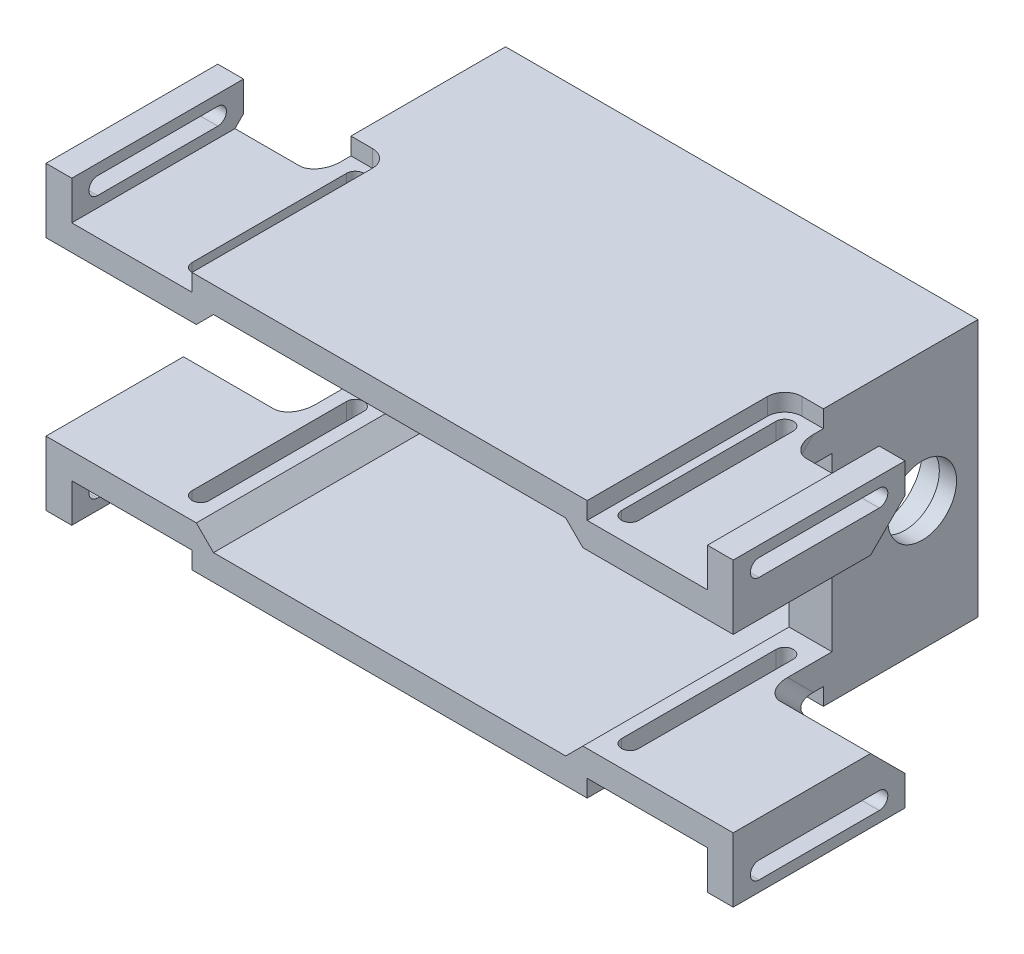
from build123d import *

# Parameters (mm, degrees)
SKIZZE2_W                       = 55
SKIZZE2_H                       = 30
SKIZZE2_W_2                     = 45
SKIZZE2_H_2                     = 24
AUFSATZ_LINEAR_AUSTRAGEN1_DEPTH = 41
SKIZZE5_W                       = 55
SKIZZE5_H                       = 20
SCHNITT_LINEAR_AUSTRAGEN3_DEPTH = 24
SKIZZE4_R                       = 4
SCHNITT_LINEAR_AUSTRAGEN1_DEPTH = 51
SKIZZE4_3_R                     = 5
SCHNITT_LINEAR_AUSTRAGEN2_DEPTH = 3
SCHNITT_LINEAR_AUSTRAGEN4_DEPTH = 5
SCHNITT_LINEAR_AUSTRAGEN5_DEPTH = 2
AUFSATZ_LINEAR_AUSTRAGEN2_DEPTH = 20
SCHNITT_LINEAR_AUSTRAGEN6_DEPTH = 4
SPIEGELN1_COPY_1_DEPTH          = 5
SPIEGELN1_COPY_2_DEPTH          = 2
SPIEGELN1_COPY_3_DEPTH          = 20
SPIEGELN1_COPY_4_DEPTH          = 4
FASE2_SIZE                      = 2
FASE3_SIZE                      = 4
VERRUNDUNG1_R                   = 2


with BuildPart() as part:
    # Skizze2 → Aufsatz-Linear austragen1 (new body)
    with BuildSketch(Plane.XY.offset(82)):
        Rectangle(SKIZZE2_W, SKIZZE2_H)
        Rectangle(SKIZZE2_W_2, SKIZZE2_H_2, mode=Mode.SUBTRACT)
    extrude(amount=-AUFSATZ_LINEAR_AUSTRAGEN1_DEPTH)

    # Skizze5 → Schnitt-Linear austragen3 (cut)
    with BuildSketch(Plane.XY.offset(82)):
        Rectangle(SKIZZE5_W, SKIZZE5_H)
    extrude(amount=-SCHNITT_LINEAR_AUSTRAGEN3_DEPTH, mode=Mode.SUBTRACT)

    # Skizze4 → Schnitt-Linear austragen1 (cut, through all)
    with BuildSketch(Plane(origin=(22.5, 0, 0), x_dir=(0, 0, -1), z_dir=(1, 0, 0))):
        with Locations((-47.5, 0)):
            Circle(SKIZZE4_R)
    schnitt_linear_austragen1 = extrude(amount=-SCHNITT_LINEAR_AUSTRAGEN1_DEPTH, mode=Mode.SUBTRACT)

    # Skizze4_3 → Schnitt-Linear austragen2 (cut)
    with BuildSketch(Plane(origin=(22.5, 0, 0), x_dir=(0, 0, -1), z_dir=(1, 0, 0))):
        with Locations((-47.5, 0)):
            Circle(SKIZZE4_3_R)
    schnitt_linear_austragen2 = extrude(amount=SCHNITT_LINEAR_AUSTRAGEN2_DEPTH, mode=Mode.SUBTRACT)

    # Skizze6 → Schnitt-Linear austragen4 (cut)
    with BuildSketch(Plane(origin=(0, 15, 0), x_dir=(1, 0, 0), z_dir=(0, 1, 0))):
        with BuildLine():
            Line((26, -61), (26, -79))
            ThreePointArc((26, -79), (25, -80), (24, -79))
            Line((24, -79), (24, -61))
            ThreePointArc((24, -61), (25, -60), (26, -61))
        make_face()
    schnitt_linear_austragen4 = extrude(amount=-SCHNITT_LINEAR_AUSTRAGEN4_DEPTH, mode=Mode.SUBTRACT)

    # Skizze6_3 → Schnitt-Linear austragen5 (cut)
    with BuildSketch(Plane(origin=(0, 15, 0), x_dir=(1, 0, 0), z_dir=(0, 1, 0))):
        with BuildLine():
            Line((23, -61), (23, -79))
            ThreePointArc((23, -79), (25, -81), (27, -79))
            Line((27, -79), (27, -61))
            ThreePointArc((27, -61), (25, -59), (23, -61))
        make_face()
        with BuildLine():
            ThreePointArc((24, -79), (25, -80), (26, -79))
            Line((26, -79), (26, -61))
            ThreePointArc((26, -61), (25, -60), (24, -61))
            Line((24, -61), (24, -79))
        make_face(mode=Mode.SUBTRACT)
        with BuildLine():
            ThreePointArc((25, -59), (26.414213562, -59.585786438), (27, -61))
            Line((27, -61), (27, -79))
            ThreePointArc((27, -79), (25, -81), (23, -79))
            Line((23, -79), (23, -82))
            Line((23, -82), (27.5, -82))
            Line((27.5, -82), (27.5, -59))
            Line((27.5, -59), (25, -59))
        make_face()
    schnitt_linear_austragen5 = extrude(amount=-SCHNITT_LINEAR_AUSTRAGEN5_DEPTH, mode=Mode.SUBTRACT)

    # Skizze8 → Aufsatz-Linear austragen2 (add)
    with BuildSketch(Plane.XY.offset(82)):
        Polygon((27.5, 13), (37, 13), (37, 17.5), (40, 17.5), (40, 10), (27.5, 10), align=None)
    aufsatz_linear_austragen2 = extrude(amount=-AUFSATZ_LINEAR_AUSTRAGEN2_DEPTH)

    # Skizze9 → Schnitt-Linear austragen6 (cut, through all)
    with BuildSketch(Plane.ZY.offset(-37)):
        with BuildLine():
            Line((65, 16.25), (79, 16.25))
            ThreePointArc((79, 16.25), (80, 15.25), (79, 14.25))
            Line((79, 14.25), (65, 14.25))
            ThreePointArc((65, 14.25), (64, 15.25), (65, 16.25))
        make_face()
    schnitt_linear_austragen6 = extrude(amount=-SCHNITT_LINEAR_AUSTRAGEN6_DEPTH, mode=Mode.SUBTRACT)

    # Spiegeln2: Schnitt-Linear austragen4, Schnitt-Linear austragen5, Aufsatz-Linear austragen2, Schnitt-Linear austragen6 across plane
    add(schnitt_linear_austragen4.mirror(Plane.ZX), mode=Mode.SUBTRACT)
    add(schnitt_linear_austragen5.mirror(Plane.ZX), mode=Mode.SUBTRACT)
    add(aufsatz_linear_austragen2.mirror(Plane.ZX))
    add(schnitt_linear_austragen6.mirror(Plane.ZX), mode=Mode.SUBTRACT)

    # Spiegeln1: Schnitt-Linear austragen2, Schnitt-Linear austragen1, Schnitt-Linear austragen4, Schnitt-Linear austragen5, Aufsatz-Linear austragen2, Schnitt-Linear austragen6 across plane
    add(schnitt_linear_austragen2.mirror(Plane(origin=(0, 0, 0), x_dir=(0, 0, 1), z_dir=(1, 0, 0))), mode=Mode.SUBTRACT)
    add(schnitt_linear_austragen1.mirror(Plane(origin=(0, 0, 0), x_dir=(0, 0, 1), z_dir=(1, 0, 0))), mode=Mode.SUBTRACT)
    add(schnitt_linear_austragen4.mirror(Plane(origin=(0, 0, 0), x_dir=(0, 0, 1), z_dir=(1, 0, 0))), mode=Mode.SUBTRACT)
    add(schnitt_linear_austragen5.mirror(Plane(origin=(0, 0, 0), x_dir=(0, 0, 1), z_dir=(1, 0, 0))), mode=Mode.SUBTRACT)
    add(aufsatz_linear_austragen2.mirror(Plane(origin=(0, 0, 0), x_dir=(0, 0, 1), z_dir=(1, 0, 0))))
    add(schnitt_linear_austragen6.mirror(Plane(origin=(0, 0, 0), x_dir=(0, 0, 1), z_dir=(1, 0, 0))), mode=Mode.SUBTRACT)

    # Spiegeln1 copy 1 sketch → Spiegeln1 copy 1 (cut)
    with BuildSketch(Plane(origin=(0, -15, 0), x_dir=(-1, 0, 0), z_dir=(0, -1, 0))):
        with BuildLine():
            Line((26, -61), (26, -79))
            ThreePointArc((26, -79), (25, -80), (24, -79))
            Line((24, -79), (24, -61))
            ThreePointArc((24, -61), (25, -60), (26, -61))
        make_face()
    extrude(amount=-SPIEGELN1_COPY_1_DEPTH, mode=Mode.SUBTRACT)

    # Spiegeln1 copy 2 sketch → Spiegeln1 copy 2 (cut)
    with BuildSketch(Plane(origin=(0, -15, 0), x_dir=(-1, 0, 0), z_dir=(0, -1, 0))):
        with BuildLine():
            Line((23, -61), (23, -79))
            ThreePointArc((23, -79), (25, -81), (27, -79))
            Line((27, -79), (27, -61))
            ThreePointArc((27, -61), (25, -59), (23, -61))
        make_face()
        with BuildLine():
            ThreePointArc((24, -79), (25, -80), (26, -79))
            Line((26, -79), (26, -61))
            ThreePointArc((26, -61), (25, -60), (24, -61))
            Line((24, -61), (24, -79))
        make_face(mode=Mode.SUBTRACT)
        with BuildLine():
            ThreePointArc((25, -59), (26.414213562, -59.585786438), (27, -61))
            Line((27, -61), (27, -79))
            ThreePointArc((27, -79), (25, -81), (23, -79))
            Line((23, -79), (23, -82))
            Line((23, -82), (27.5, -82))
            Line((27.5, -82), (27.5, -59))
            Line((27.5, -59), (25, -59))
        make_face()
    extrude(amount=-SPIEGELN1_COPY_2_DEPTH, mode=Mode.SUBTRACT)

    # Spiegeln1 copy 3 sketch → Spiegeln1 copy 3 (add)
    with BuildSketch(Plane(origin=(0, 0, 82), x_dir=(-1, 0, 0), z_dir=(0, 0, 1))):
        Polygon((27.5, 13), (37, 13), (37, 17.5), (40, 17.5), (40, 10), (27.5, 10), align=None)
    extrude(amount=-SPIEGELN1_COPY_3_DEPTH)

    # Spiegeln1 copy 4 sketch → Spiegeln1 copy 4 (cut, through all)
    with BuildSketch(Plane(origin=(-37, 0, 0), x_dir=(0, 0, 1), z_dir=(1, 0, 0))):
        with BuildLine():
            Line((65, 16.25), (79, 16.25))
            ThreePointArc((79, 16.25), (80, 15.25), (79, 14.25))
            Line((79, 14.25), (65, 14.25))
            ThreePointArc((65, 14.25), (64, 15.25), (65, 16.25))
        make_face()
    extrude(amount=-SPIEGELN1_COPY_4_DEPTH, mode=Mode.SUBTRACT)

    # Fase2
    fase2_edges = [part.edges().sort_by_distance(p)[0] for p in [
        (-22.5, 12, 61.5),
        (-22.5, -12, 61.5),
        (22.5, -12, 61.5),
        (22.5, 12, 61.5),
    ]]
    chamfer(fase2_edges, length=FASE2_SIZE)

    # Fase3
    fase3_edges = [part.edges().sort_by_distance(p)[0] for p in [
        (-33.75, 10, 62),
        (-33.75, -10, 62),
        (33.75, -10, 62),
        (33.75, 10, 62),
    ]]
    chamfer(fase3_edges, length=FASE3_SIZE)

    # Verrundung1
    verrundung1_edges = [part.edges().sort_by_distance(p)[0] for p in [
        (-27.5, 11.5, 64.5),
        (-27.5, -11.5, 64.5),
        (27.5, -11.5, 64.5),
        (27.5, 11.5, 64.5),
    ]]
    fillet(verrundung1_edges, radius=VERRUNDUNG1_R)


solid = part.part
